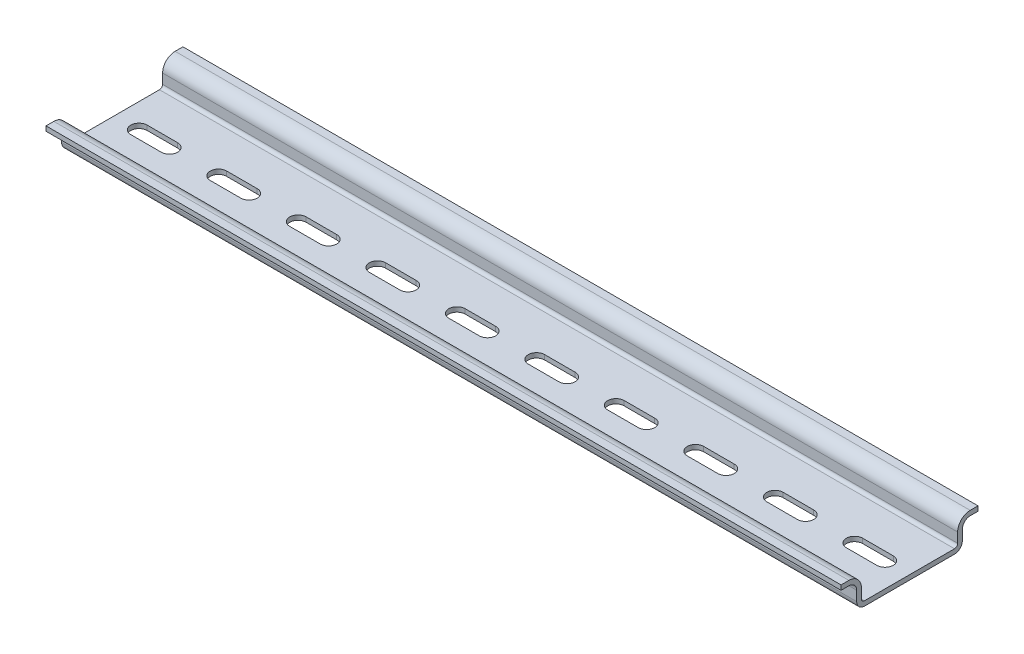
from build123d import *

# Parameters (mm, degrees)
EXTRUDE_THIN1_DEPTH = 101.6
CUT_EXTRUDE1_DEPTH  = 1.2
LPATTERN1_COUNT     = 10
LPATTERN1_PITCH     = 20.32


with BuildPart() as part:
    # Sketch1 → Extrude-Thin1 (new body, symmetric)
    with BuildSketch(Plane(origin=(0, 0, 0), x_dir=(0, 0, -1), z_dir=(1, 0, 0))):
        with BuildLine():
            Line((-17.5, 6.5), (-15.5, 6.5))
            ThreePointArc((-15.5, 6.5), (-14.085786438, 5.914213562), (-13.5, 4.5))
            Line((-13.5, 4.5), (-13.5, 2))
            ThreePointArc((-13.5, 2), (-12.914213562, 0.585786438), (-11.5, 0))
            Line((-11.5, 0), (11.5, 0))
            ThreePointArc((11.5, 0), (12.914213562, 0.585786438), (13.5, 2))
            Line((13.5, 2), (13.5, 4.5))
            ThreePointArc((13.5, 4.5), (14.085786438, 5.914213562), (15.5, 6.5))
            Line((15.5, 6.5), (17.5, 6.5))
            Line((17.5, 6.5), (17.5, 7.7))
            Line((17.5, 7.7), (15.5, 7.7))
            ThreePointArc((15.5, 7.7), (13.2372583, 6.7627417), (12.3, 4.5))
            Line((12.3, 4.5), (12.3, 2))
            ThreePointArc((12.3, 2), (12.065685425, 1.434314575), (11.5, 1.2))
            Line((11.5, 1.2), (-11.5, 1.2))
            ThreePointArc((-11.5, 1.2), (-12.065685425, 1.434314575), (-12.3, 2))
            Line((-12.3, 2), (-12.3, 4.5))
            ThreePointArc((-12.3, 4.5), (-13.2372583, 6.7627417), (-15.5, 7.7))
            Line((-15.5, 7.7), (-17.5, 7.7))
            Line((-17.5, 7.7), (-17.5, 6.5))
        make_face()
    extrude(amount=EXTRUDE_THIN1_DEPTH, both=True)

    # Sketch2 → Cut-Extrude1 (cut)
    with BuildSketch(Plane.XZ):
        with BuildLine():
            Line((87.54, 2.1), (95.34, 2.1))
            ThreePointArc((95.34, 2.1), (97.44, 0), (95.34, -2.1))
            Line((95.34, -2.1), (87.54, -2.1))
            ThreePointArc((87.54, -2.1), (85.44, 0), (87.54, 2.1))
        make_face()
    cut_extrude1 = extrude(amount=-CUT_EXTRUDE1_DEPTH, mode=Mode.SUBTRACT)

    # LPattern1: Cut-Extrude1 ×10
    with Locations(*[(-i * LPATTERN1_PITCH, 0, 0) for i in range(1, LPATTERN1_COUNT)]):
        add(cut_extrude1, mode=Mode.SUBTRACT)


solid = part.part
